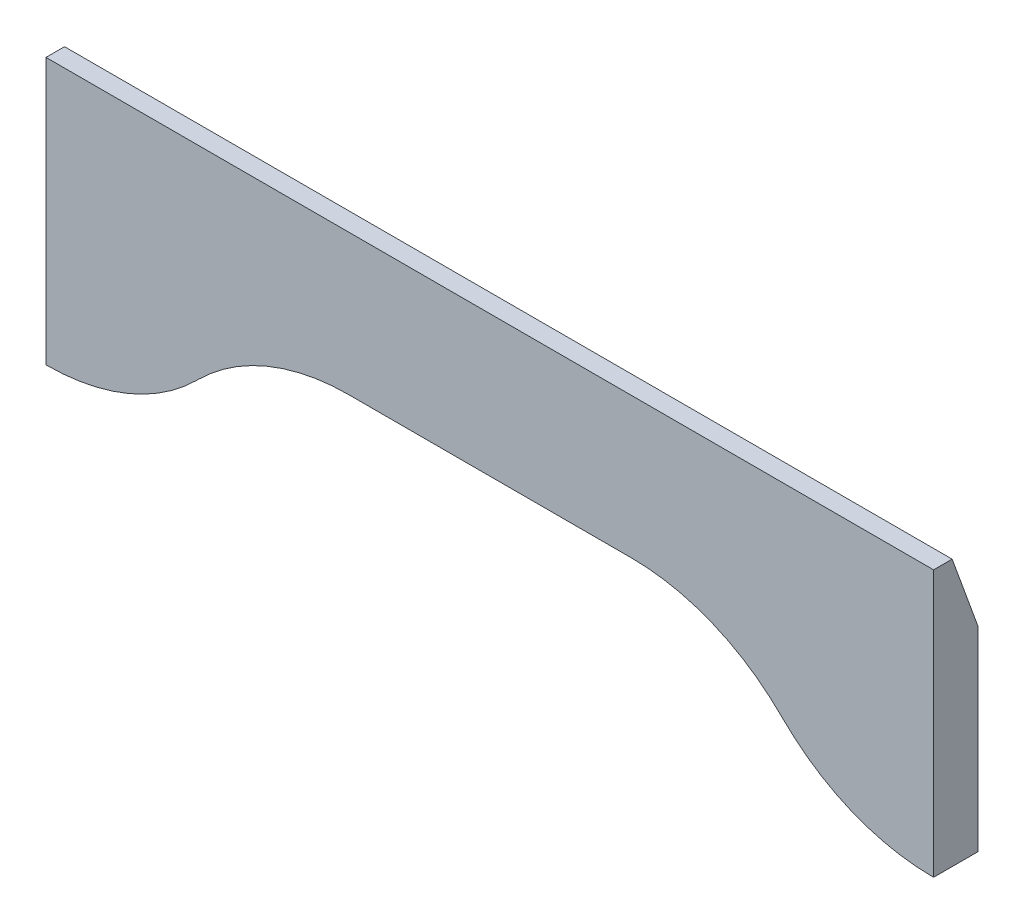
from build123d import *

# Parameters (mm, degrees)
SKETCH1_W           = 127
SKETCH1_H           = 38.1
BOSS_EXTRUDE1_DEPTH = 6.35
CUT_EXTRUDE1_DEPTH  = 6.35
FILLET1_R           = 30.48
CHAMFER1_SIZE       = 10.16
CHAMFER1_SIZE2      = 3.69793758


with BuildPart() as part:
    # Sketch1 → Boss-Extrude1 (new body)
    with BuildSketch(Plane.XY):
        with Locations((63.5, 19.05)):
            Rectangle(SKETCH1_W, SKETCH1_H)
    extrude(amount=BOSS_EXTRUDE1_DEPTH)

    # Sketch2 → Cut-Extrude1 (cut)
    with BuildSketch(Plane.XY.offset(6.35)):
        Polygon((12.7, 0), (30.660512242, 17.960512242), (96.339487758, 17.960512242), (114.3, 0), align=None)
    extrude(amount=-CUT_EXTRUDE1_DEPTH, mode=Mode.SUBTRACT)

    # Fillet1
    fillet1_edges = [part.edges().sort_by_distance(p)[0] for p in [
        (114.3, 0, 3.175),
        (12.7, 0, 3.175),
        (30.660512242, 17.960512242, 3.175),
        (96.339487758, 17.960512242, 3.175),
    ]]
    fillet(fillet1_edges, radius=FILLET1_R)

    # Chamfer1
    chamfer1_edges = [part.edges().sort_by_distance(p)[0] for p in [
        (63.5, 38.1, 0),
    ]]
    chamfer1_side = [part.faces().sort_by_distance(p)[0] for p in [
        (63.5, 24.04441534, 0),
    ]]
    chamfer(chamfer1_edges, length=CHAMFER1_SIZE, length2=CHAMFER1_SIZE2, reference=chamfer1_side[0])


solid = part.part
